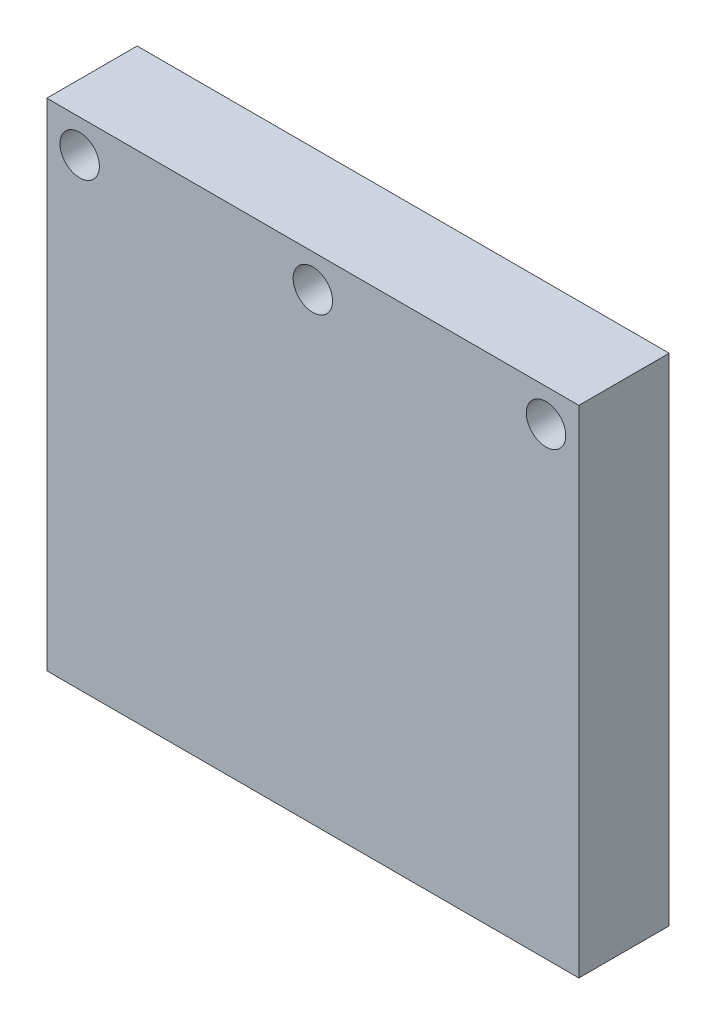
from build123d import *

# Parameters (mm, degrees)
SKETCH1_W                = 16.2
SKETCH1_H                = 15.1
BOSS_EXTRUDE1_DEPTH      = 2.75
M1_CLEARANCE_HOLE2_D     = 1.2
M1_CLEARANCE_HOLE2_DEPTH = 2.75


with BuildPart() as part:
    # Sketch1 → Boss-Extrude1 (new body)
    with BuildSketch(Plane.XY):
        Rectangle(SKETCH1_W, SKETCH1_H)
    extrude(amount=BOSS_EXTRUDE1_DEPTH)

    # Sketch3 → M1 Clearance Hole1 (revolve, cut)
    with BuildSketch(Plane(origin=(7.1, 6.55, 2.75), x_dir=(0, -1, 0), z_dir=(1, 0, 0))):
        Polygon((0, 0), (0, 3.510516371), (0.6, 3.15), (0.6, 0), align=None)
    m1_clearance_hole1 = revolve(axis=Axis((7.1, 6.55, 9.1), (0, 0, -1)), mode=Mode.SUBTRACT)

    # Mirror1: M1 Clearance Hole1 across plane
    add(m1_clearance_hole1.mirror(Plane(origin=(0, 0, 0), x_dir=(0, 0, 1), z_dir=(1, 0, 0))), mode=Mode.SUBTRACT)

    # M1 Clearance Hole2
    with Locations(Plane.XY.offset(2.75)):
        with Locations((0, 6.55)):
            Hole(M1_CLEARANCE_HOLE2_D / 2, depth=M1_CLEARANCE_HOLE2_DEPTH)


solid = part.part
